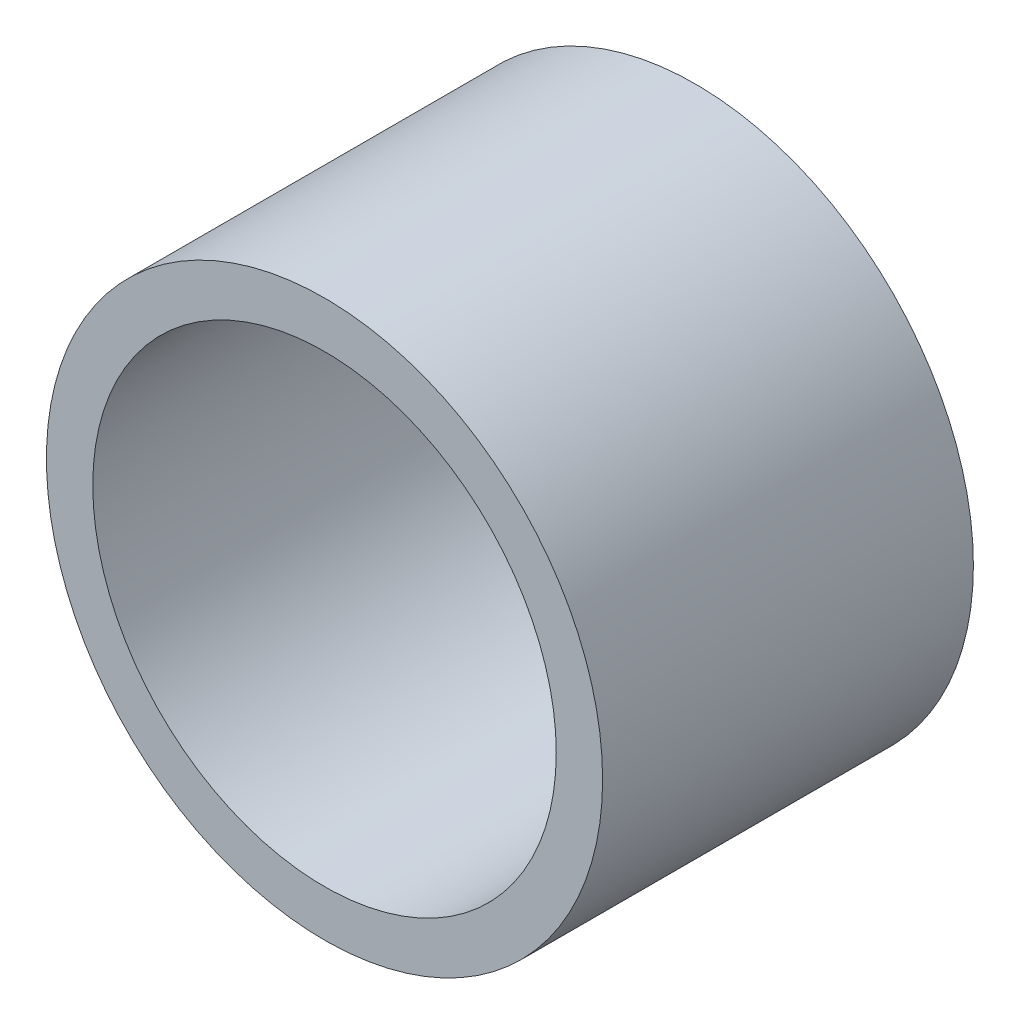
from build123d import *

# Parameters (mm, degrees)
SKETCH1_R     = 19.05
SKETCH1_R_2   = 15.875
HOUSING_DEPTH = 25.4


with BuildPart() as part:
    # Sketch1 → Housing (new body)
    with BuildSketch(Plane.XY):
        Circle(SKETCH1_R)
        Circle(SKETCH1_R_2, mode=Mode.SUBTRACT)
    extrude(amount=HOUSING_DEPTH)


solid = part.part
